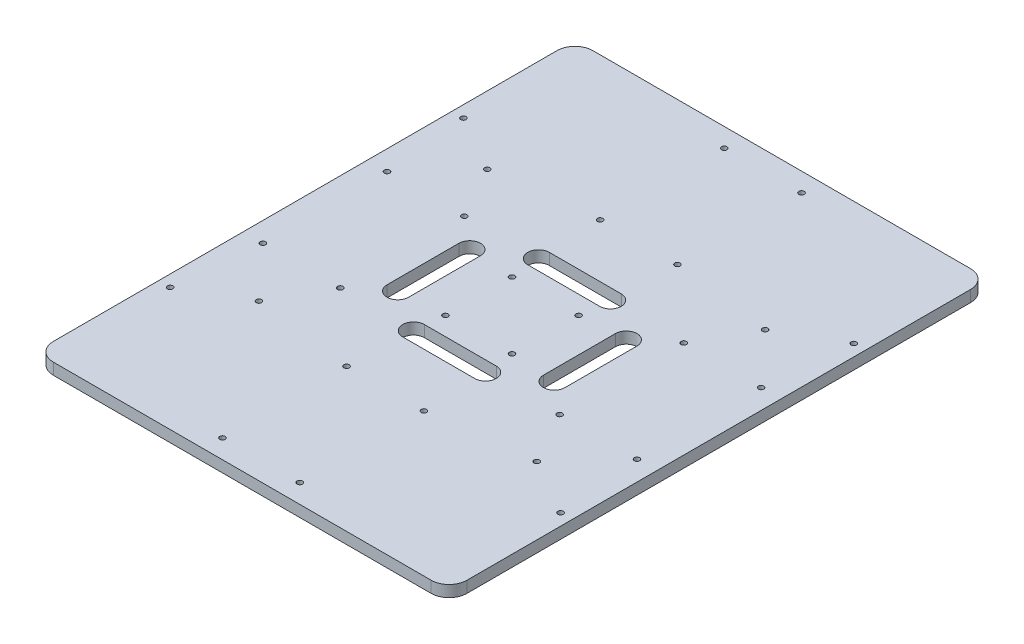
from build123d import *

# Parameters (mm, degrees)
EXTRUDE_1_DEPTH     = 6.35
SKETCH_2_R          = 1.5
CUT_EXTRUDE_1_DEPTH = 7.35


with BuildPart() as part:
    # 草图1 → 凸台-拉伸1 (new body)
    with BuildSketch(Plane(origin=(0, 0, 0), x_dir=(1, 0, 0), z_dir=(0, 1, 0))):
        with BuildLine():
            Line((-64.584796248, 56.678842543), (-64.584796248, -223.321157457))
            ThreePointArc((-64.584796248, -223.321157457), (-61.65586406, -230.392225269), (-54.584796248, -233.321157457))
            Line((-54.584796248, -233.321157457), (155.415203752, -233.321157457))
            ThreePointArc((155.415203752, -233.321157457), (162.486271564, -230.392225269), (165.415203752, -223.321157457))
            Line((165.415203752, -223.321157457), (165.415203752, 56.678842543))
            ThreePointArc((165.415203752, 56.678842543), (162.486271564, 63.749910354), (155.415203752, 66.678842543))
            Line((155.415203752, 66.678842543), (-54.584796248, 66.678842543))
            ThreePointArc((-54.584796248, 66.678842543), (-61.65586406, 63.749910354), (-64.584796248, 56.678842543))
        make_face()
    extrude(amount=EXTRUDE_1_DEPTH)

    # 草图2 → 切除-拉伸1 (cut, through all)
    with BuildSketch(Plane(origin=(0, 6.35, 0), x_dir=(1, 0, 0), z_dir=(0, 1, 0))):
        with Locations((68.915203752, -64.821157457)):
            Circle(SKETCH_2_R)
        with Locations((68.915203752, -101.821157457)):
            Circle(SKETCH_2_R)
        with Locations((31.915203752, -101.821157457)):
            Circle(SKETCH_2_R)
        with Locations((31.915203752, -64.821157457)):
            Circle(SKETCH_2_R)
        with Locations((111.415203752, -48.821157457)):
            Circle(SKETCH_2_R)
        with Locations((154.415203752, -48.821157457)):
            Circle(SKETCH_2_R)
        with Locations((111.415203752, -117.821157457)):
            Circle(SKETCH_2_R)
        with Locations((154.415203752, -117.821157457)):
            Circle(SKETCH_2_R)
        with Locations((-53.584796248, -117.821157457)):
            Circle(SKETCH_2_R)
        with Locations((-10.584796248, -117.821157457)):
            Circle(SKETCH_2_R)
        with Locations((-53.584796248, -48.821157457)):
            Circle(SKETCH_2_R)
        with Locations((-10.584796248, -48.821157457)):
            Circle(SKETCH_2_R)
        with Locations((28.915203752, -222.821157457)):
            Circle(SKETCH_2_R)
        with Locations((28.915203752, -153.821157457)):
            Circle(SKETCH_2_R)
        with Locations((71.915203752, -222.821157457)):
            Circle(SKETCH_2_R)
        with Locations((71.915203752, -153.821157457)):
            Circle(SKETCH_2_R)
        with Locations((71.915203752, 56.178842543)):
            Circle(SKETCH_2_R)
        with Locations((28.915203752, 56.178842543)):
            Circle(SKETCH_2_R)
        with Locations((71.915203752, -12.821157457)):
            Circle(SKETCH_2_R)
        with Locations((28.915203752, -12.821157457)):
            Circle(SKETCH_2_R)
        with Locations((127.665203752, -146.791157457)):
            Circle(SKETCH_2_R)
        with Locations((158.945203752, -164.851157457)):
            Circle(SKETCH_2_R)
        with Locations((158.945203752, -1.791157457)):
            Circle(SKETCH_2_R)
        with Locations((127.665203752, -19.851157457)):
            Circle(SKETCH_2_R)
        with Locations((-58.114796248, -1.791157457)):
            Circle(SKETCH_2_R)
        with Locations((-26.834796248, -19.851157457)):
            Circle(SKETCH_2_R)
        with Locations((-58.114796248, -164.851157457)):
            Circle(SKETCH_2_R)
        with Locations((-26.834796248, -146.791157457)):
            Circle(SKETCH_2_R)
        with BuildLine():
            Line((30.415203752, -124.071157457), (70.415203752, -124.071157457))
            ThreePointArc((70.415203752, -124.071157457), (76.415203752, -118.071157457), (70.415203752, -112.071157457))
            Line((70.415203752, -112.071157457), (30.415203752, -112.071157457))
            ThreePointArc((30.415203752, -112.071157457), (24.415203752, -118.071157457), (30.415203752, -124.071157457))
        make_face()
        with BuildLine():
            Line((30.415203752, -42.571157457), (70.415203752, -42.571157457))
            ThreePointArc((70.415203752, -42.571157457), (76.415203752, -48.571157457), (70.415203752, -54.571157457))
            Line((70.415203752, -54.571157457), (30.415203752, -54.571157457))
            ThreePointArc((30.415203752, -54.571157457), (24.415203752, -48.571157457), (30.415203752, -42.571157457))
        make_face()
        with BuildLine():
            Line((12.915203752, -63.321157457), (12.915203752, -103.321157457))
            ThreePointArc((12.915203752, -103.321157457), (6.915203752, -109.321157457), (0.915203752, -103.321157457))
            Line((0.915203752, -103.321157457), (0.915203752, -63.321157457))
            ThreePointArc((0.915203752, -63.321157457), (6.915203752, -57.321157457), (12.915203752, -63.321157457))
        make_face()
        with BuildLine():
            Line((87.915203752, -63.321157457), (87.915203752, -103.321157457))
            ThreePointArc((87.915203752, -103.321157457), (93.915203752, -109.321157457), (99.915203752, -103.321157457))
            Line((99.915203752, -103.321157457), (99.915203752, -63.321157457))
            ThreePointArc((99.915203752, -63.321157457), (93.915203752, -57.321157457), (87.915203752, -63.321157457))
        make_face()
    extrude(amount=-CUT_EXTRUDE_1_DEPTH, mode=Mode.SUBTRACT)


solid = part.part
